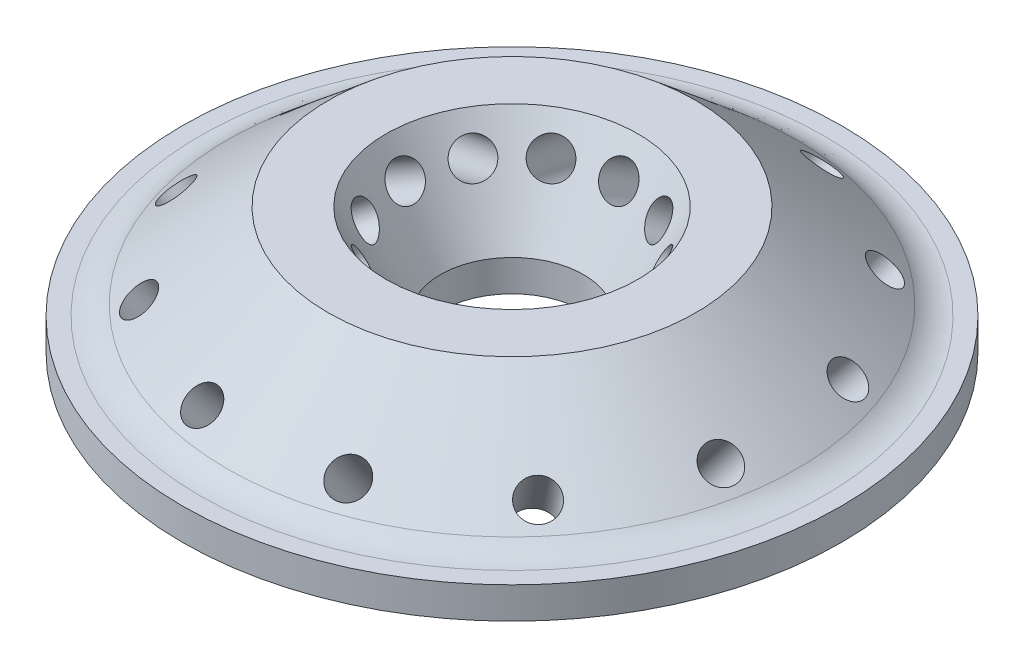
from build123d import *

# Parameters (mm, degrees)
SKETCH1_R                = 69.85
BOSS_EXTRUDE1_DEPTH      = 8.89
SKETCH2_R                = 22.225
SKETCH2_R_2              = 15.24
BOSS_EXTRUDE2_DEPTH      = 11.43
SKETCH13_R               = 41.275
SKETCH13_R_2             = 33.02
SKETCH13_R_3             = 25.4
SKETCH13_R_4             = 14.2875
SKETCH13_R_5             = 7.62
CUT_EXTRUDE10_DEPTH      = 5.08
FILLET3_R                = 2.54
CUT_EXTRUDE5_START       = -2.54
SKETCH10_R               = 2.1828125
CUT_EXTRUDE5_DEPTH       = 33.02
CUT_EXTRUDE6_START       = -3.175
SKETCH11_R               = 2.1828125
CUT_EXTRUDE6_DEPTH       = 22.225
CIRPATTERN1_COUNT        = 12
SKETCH12_R               = 2.54
CUT_EXTRUDE7_DEPTH       = 9.8900001
CIRPATTERN2_COUNT        = 12
SKETCH15_R               = 1.3890625
CUT_EXTRUDE11_DEPTH      = 9.8900001
CIRPATTERN3_COUNT        = 8
SKETCH16_R               = 30.2133
SKETCH16_R_2             = 27.5717
CUT_EXTRUDE12_DEPTH      = 1.3208
SKETCH17_R               = 11.9507
SKETCH17_R_2             = 9.3091
CUT_EXTRUDE13_DEPTH      = 1.3208
SKETCH18_R               = 52.4383
SKETCH18_R_2             = 49.7967
CUT_EXTRUDE14_DEPTH      = 1.3208
SKETCH19_R               = 52.4383
SKETCH19_R_2             = 49.7967
CUT_EXTRUDE15_DEPTH      = 1.3208
SKETCH21_R               = 1.3890625
CUT_EXTRUDE17_DEPTH      = 9.8900001
FILLET2_R                = 5.08
SKETCH23_R               = 75.594264534
SKETCH23_R_2             = 39.829553563
CUT_EXTRUDE18_DEPTH      = 13.7508001
CUT_EXTRUDE18_DEPTH_BACK = 8.5692001
SKETCH24_R               = 58.815023668
CUT_EXTRUDE19_DEPTH      = 5.08
SKETCH25_R               = 8.640886423
CUT_EXTRUDE20_DEPTH      = 4.8100001


with BuildPart() as part:
    # Sketch1 → Boss-Extrude1 (new body)
    with BuildSketch(Plane(origin=(0, 0, 0), x_dir=(1, 0, 0), z_dir=(0, 1, 0))):
        Circle(SKETCH1_R)
    extrude(amount=BOSS_EXTRUDE1_DEPTH)

    # Sketch2 → Boss-Extrude2 (add)
    with BuildSketch(Plane(origin=(0, 8.89, 0), x_dir=(1, 0, 0), z_dir=(0, 1, 0))):
        Circle(SKETCH2_R)
        Circle(SKETCH2_R_2, mode=Mode.SUBTRACT)
    extrude(amount=BOSS_EXTRUDE2_DEPTH)

    # Sketch7 → Revolve2 (revolve)
    with BuildSketch(Plane.XY):
        Polygon((-15.24, 20.32), (-15.24, 8.89), (-8.640886423, 8.89), align=None)
    revolve(axis=Axis((0, 0, 0), (0, 1, 0)))

    # Sketch9 → Revolve3 (revolve)
    with BuildSketch(Plane(origin=(0, 0, 0), x_dir=(-0.945518576, 0, 0.325568154), z_dir=(-0.325568154, 0, -0.945518576))):
        Polygon((-22.225, 20.32), (-22.225, 8.89), (-35.846743563, 8.89), align=None)
    revolve(axis=Axis((0, 0, 0), (0, 1, 0)))

    # Sketch13 → Cut-Extrude10 (cut)
    with BuildSketch(Plane.XZ):
        Circle(SKETCH13_R)
        Circle(SKETCH13_R_2, mode=Mode.SUBTRACT)
        Circle(SKETCH13_R_3)
        Circle(SKETCH13_R_4, mode=Mode.SUBTRACT)
        Circle(SKETCH13_R_5)
    extrude(amount=-CUT_EXTRUDE10_DEPTH, mode=Mode.SUBTRACT)

    # Fillet3
    fillet3_edges = [part.edges().sort_by_distance(p)[0] for p in [
        (-25.4, 5.08, 0),
        (-14.2875, 5.08, 0),
        (-7.62, 5.08, 0),
        (-41.275, 5.08, 0),
        (-33.02, 5.08, 0),
    ]]
    fillet(fillet3_edges, radius=FILLET3_R)

    # Sketch10 → Cut-Extrude5 (cut)
    with BuildSketch(Plane(origin=(-2.631181898, -1.519113577, 0), x_dir=(0.5, -0.866025404, 0), z_dir=(-0.866025404, -0.5, 0)).offset(CUT_EXTRUDE5_START)):
        with Locations((-20.772636205, 0)):
            Circle(SKETCH10_R)
    cut_extrude5 = extrude(amount=CUT_EXTRUDE5_DEPTH, mode=Mode.SUBTRACT)

    # Sketch11 → Cut-Extrude6 (cut)
    with BuildSketch(Plane(origin=(18.143065598, 22.86794164, -6.247158475), x_dir=(0.724309251, -0.64278761, -0.249399676), z_dir=(-0.607767625, -0.766044443, 0.209271176)).offset(CUT_EXTRUDE6_START)):
        with Locations((16.663893519, 0)):
            Circle(SKETCH11_R)
    cut_extrude6 = extrude(amount=CUT_EXTRUDE6_DEPTH, mode=Mode.SUBTRACT)

    # CirPattern1: Cut-Extrude5, Cut-Extrude6 ×12 about axis
    cirpattern1_axis = Axis((0, 8.89, 0), (0, -1, 0))
    for i in range(1, CIRPATTERN1_COUNT):
        add(cut_extrude5.rotate(cirpattern1_axis, i * 360 / CIRPATTERN1_COUNT), mode=Mode.SUBTRACT)
        add(cut_extrude6.rotate(cirpattern1_axis, i * 360 / CIRPATTERN1_COUNT), mode=Mode.SUBTRACT)

    # Sketch12 → Cut-Extrude7 (cut, through all)
    with BuildSketch(Plane(origin=(0, 8.89, 0), x_dir=(1, 0, 0), z_dir=(0, 1, 0))):
        with Locations((60.96, 0)):
            Circle(SKETCH12_R)
    cut_extrude7 = extrude(amount=-CUT_EXTRUDE7_DEPTH, mode=Mode.SUBTRACT)

    # CirPattern2: Cut-Extrude7 ×12 about axis
    cirpattern2_axis = Axis((0, 0, 0), (0, 1, 0))
    for i in range(1, CIRPATTERN2_COUNT):
        add(cut_extrude7.rotate(cirpattern2_axis, i * 360 / CIRPATTERN2_COUNT), mode=Mode.SUBTRACT)

    # Sketch15 → Cut-Extrude11 (cut, through all)
    with BuildSketch(Plane(origin=(0, 8.89, 0), x_dir=(1, 0, 0), z_dir=(0, 1, 0))):
        with Locations((0, 5.715)):
            Circle(SKETCH15_R)
    cut_extrude11 = extrude(amount=-CUT_EXTRUDE11_DEPTH, mode=Mode.SUBTRACT)

    # CirPattern3: Cut-Extrude11 ×8 about axis
    cirpattern3_axis = Axis((0, 0, 0), (0, 1, 0))
    for i in range(1, CIRPATTERN3_COUNT):
        add(cut_extrude11.rotate(cirpattern3_axis, i * 360 / CIRPATTERN3_COUNT), mode=Mode.SUBTRACT)

    # Sketch16 → Cut-Extrude12 (cut)
    with BuildSketch(Plane.XZ):
        Circle(SKETCH16_R)
        Circle(SKETCH16_R_2, mode=Mode.SUBTRACT)
    extrude(amount=-CUT_EXTRUDE12_DEPTH, mode=Mode.SUBTRACT)

    # Sketch17 → Cut-Extrude13 (cut)
    with BuildSketch(Plane.XZ):
        Circle(SKETCH17_R)
        Circle(SKETCH17_R_2, mode=Mode.SUBTRACT)
    extrude(amount=-CUT_EXTRUDE13_DEPTH, mode=Mode.SUBTRACT)

    # Sketch18 → Cut-Extrude14 (cut)
    with BuildSketch(Plane(origin=(0, 8.89, 0), x_dir=(1, 0, 0), z_dir=(0, 1, 0))):
        Circle(SKETCH18_R)
        Circle(SKETCH18_R_2, mode=Mode.SUBTRACT)
    extrude(amount=-CUT_EXTRUDE14_DEPTH, mode=Mode.SUBTRACT)

    # Sketch19 → Cut-Extrude15 (cut)
    with BuildSketch(Plane.XZ):
        Circle(SKETCH19_R)
        Circle(SKETCH19_R_2, mode=Mode.SUBTRACT)
    extrude(amount=-CUT_EXTRUDE15_DEPTH, mode=Mode.SUBTRACT)

    # Sketch21 → Cut-Extrude17 (cut, through all)
    with BuildSketch(Plane(origin=(0, 8.89, 0), x_dir=(1, 0, 0), z_dir=(0, 1, 0))):
        Circle(SKETCH21_R)
    extrude(amount=-CUT_EXTRUDE17_DEPTH, mode=Mode.SUBTRACT)

    # Fillet2
    fillet2_edges = [part.edges().sort_by_distance(p)[0] for p in [
        (-33.893761914, 8.89, 11.670558145),
    ]]
    fillet(fillet2_edges, radius=FILLET2_R)

    # Sketch23 → Cut-Extrude18 (cut, two sides)
    with BuildSketch(Plane(origin=(0, 7.5692, 0), x_dir=(1, 0, 0), z_dir=(0, 1, 0))) as cut_extrude18_sk:
        Circle(SKETCH23_R)
        Circle(SKETCH23_R_2, mode=Mode.SUBTRACT)
    extrude(amount=CUT_EXTRUDE18_DEPTH, mode=Mode.SUBTRACT)
    extrude(cut_extrude18_sk.sketch, amount=-CUT_EXTRUDE18_DEPTH_BACK, mode=Mode.SUBTRACT)

    # Sketch24 → Cut-Extrude19 (cut)
    with BuildSketch(Plane.XZ):
        Circle(SKETCH24_R)
    extrude(amount=-CUT_EXTRUDE19_DEPTH, mode=Mode.SUBTRACT)

    # Sketch25 → Cut-Extrude20 (cut, through all)
    with BuildSketch(Plane(origin=(0, 8.89, 0), x_dir=(1, 0, 0), z_dir=(0, 1, 0))):
        Circle(SKETCH25_R)
    extrude(amount=-CUT_EXTRUDE20_DEPTH, mode=Mode.SUBTRACT)


solid = part.part
